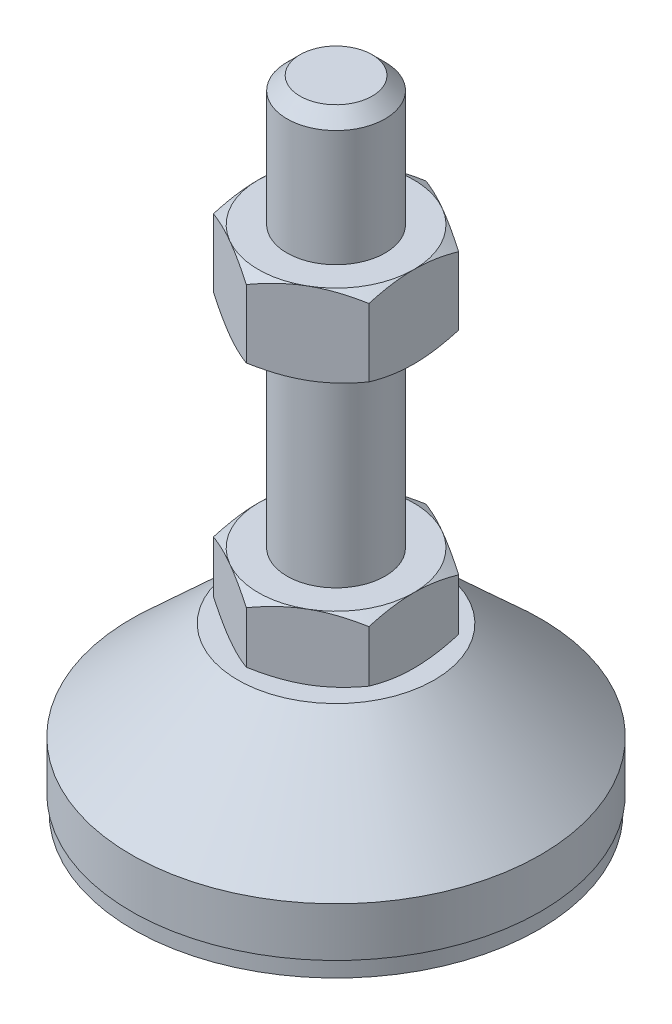
from build123d import *

# Parameters (mm, degrees)
EXTRUDE_1_DEPTH = 8
EXTRUDE_2_DEPTH = 10


with BuildPart() as part:
    # Эскиз1 → Повернуть1 (revolve)
    with BuildSketch(Plane.XY, mode=Mode.PRIVATE) as revolve_1_sk:
        Polygon((0, 0), (-24.8, 0), (-24.8, 2), (-25, 2), (-25, 8), (-12, 20), (-6, 20), (-6, 28), (-6, 76.4), (-4.4, 78), (0, 78), align=None)
    revolve(revolve_1_sk.sketch.rotate(Axis((0, 0, 0), (0, 1, 0)), 180), axis=Axis((0, 0, 0), (0, 1, 0)))  # turned: the seam where the file's is

    # Эскиз2 → Бобышка-Вытянуть1 (add)
    with BuildSketch(Plane(origin=(0, 20, 0), x_dir=(1, 0, 0), z_dir=(0, 1, 0))):
        Polygon((0, 10.969655115), (-9.5, 5.484827557), (-9.5, -5.484827557), (0, -10.969655115), (9.5, -5.484827557), (9.5, 5.484827557), align=None)
    extrude(amount=EXTRUDE_1_DEPTH)

    # Эскиз3 → Бобышка-Вытянуть2 (add)
    with BuildSketch(Plane(origin=(0, 52.2, 0), x_dir=(1, 0, 0), z_dir=(0, 1, 0))):
        Polygon((9.5, 5.484827557), (0, 10.969655115), (-9.5, 5.484827557), (-9.5, -5.484827557), (0, -10.969655115), (9.5, -5.484827557), align=None)
    extrude(amount=EXTRUDE_2_DEPTH)

    # Эскиз4 → Вырез-Повернуть2 (revolve, cut)
    with BuildSketch(Plane.XY, mode=Mode.PRIVATE) as cut_revolve_2_sk:
        Polygon((-18.160254038, 62.2), (-9.5, 62.2), (-18.160254038, 57.2), align=None)
        Polygon((-18.160254038, 52.2), (-18.160254038, 57.2), (-9.5, 52.2), align=None)
        Polygon((-16.42820323, 28), (-16.42820323, 24), (-9.5, 28), align=None)
        Polygon((-16.42820323, 24), (-16.42820323, 20), (-9.5, 20), align=None)
    revolve(cut_revolve_2_sk.sketch.rotate(Axis((0, 78, 0), (0, 1, 0)), 180), axis=Axis((0, 78, 0), (0, 1, 0)), mode=Mode.SUBTRACT)  # turned: the seam where the file's is


solid = part.part
